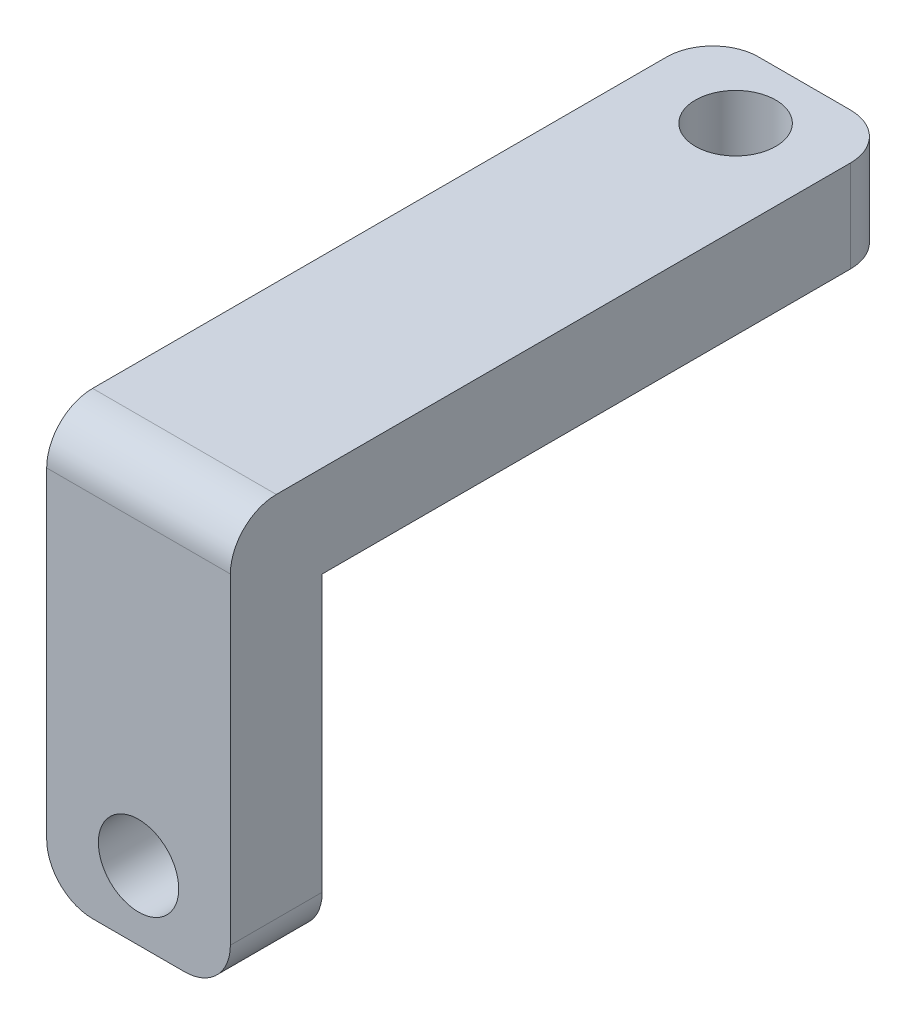
from build123d import *

# Parameters (mm, degrees)
ESQUISSE1_W        = 8
ESQUISSE1_H        = 25
ESQUISSE1_R        = 1.75
BOSS_EXTRU_1_DEPTH = 4
ESQUISSE2_W        = 8
ESQUISSE2_H        = 18
ESQUISSE2_R        = 1.75
BOSS_EXTRU_2_DEPTH = 4
CONG_1_R           = 2


with BuildPart() as part:
    # Esquisse1 → Boss.-Extru.1 (new body)
    with BuildSketch(Plane(origin=(0, 0, 0), x_dir=(1, 0, 0), z_dir=(0, 1, 0))):
        Rectangle(ESQUISSE1_W, ESQUISSE1_H)
        with Locations((0, 9.5)):
            Circle(ESQUISSE1_R, mode=Mode.SUBTRACT)
    extrude(amount=BOSS_EXTRU_1_DEPTH)

    # Esquisse2 → Boss.-Extru.2 (add)
    with BuildSketch(Plane.XY.offset(12.5)):
        with Locations((0, -5)):
            Rectangle(ESQUISSE2_W, ESQUISSE2_H)
        with Locations((0, -11)):
            Circle(ESQUISSE2_R, mode=Mode.SUBTRACT)
    extrude(amount=BOSS_EXTRU_2_DEPTH)

    # Congé1
    cong_1_edges = [part.edges().sort_by_distance(p)[0] for p in [
        (0, 4, 16.5),
        (-4, -14, 14.5),
        (4, -14, 14.5),
        (-4, 2, -12.5),
        (4, 2, -12.5),
    ]]
    fillet(cong_1_edges, radius=CONG_1_R)


solid = part.part
